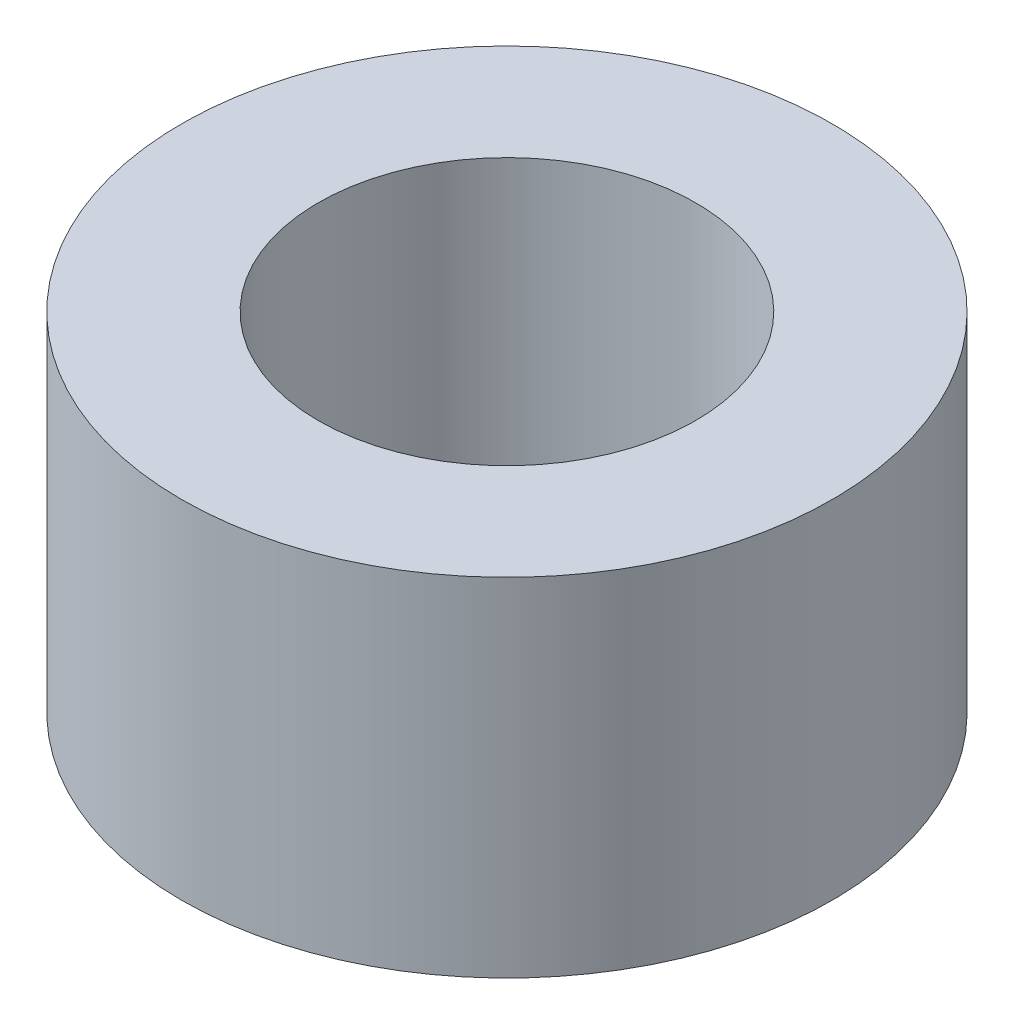
from build123d import *

# Parameters (mm, degrees)
SKETCH2_R           = 7.5
SKETCH2_R_2         = 4.35
BOSS_EXTRUDE1_DEPTH = 8


with BuildPart() as part:
    # Sketch2 → Boss-Extrude1 (new body)
    with BuildSketch(Plane(origin=(0, 0, 0), x_dir=(1, 0, 0), z_dir=(0, 1, 0))):
        Circle(SKETCH2_R)
        Circle(SKETCH2_R_2, mode=Mode.SUBTRACT)
    extrude(amount=BOSS_EXTRUDE1_DEPTH)


solid = part.part
